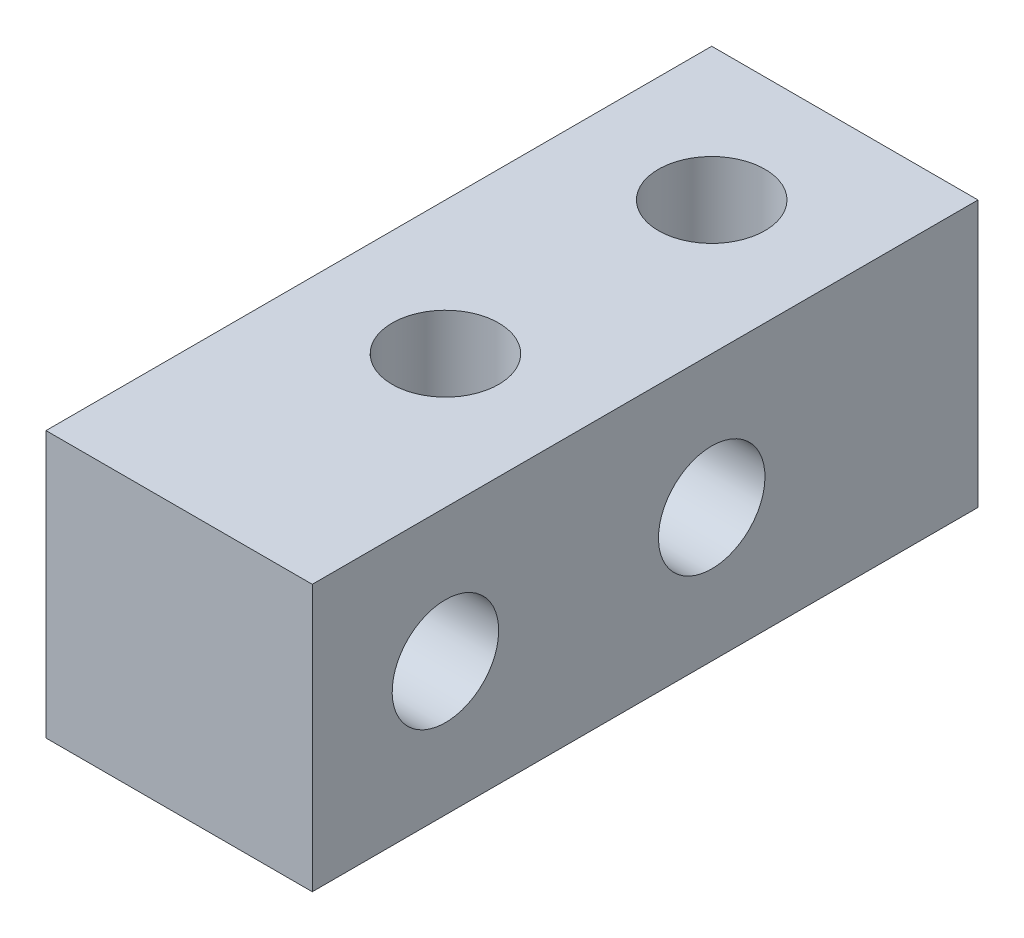
from build123d import *

# Parameters (mm, degrees)
SKETCH_1_W          = 10
SKETCH_1_H          = 10
EXTRUDE_1_DEPTH     = 12.5
SKETCH_2_R          = 2
CUT_EXTRUDE_1_DEPTH = 25
SKETCH_3_R          = 2
CUT_EXTRUDE_2_DEPTH = 25


with BuildPart() as part:
    # 草图1 → 凸台-拉伸1 (new body, symmetric)
    with BuildSketch(Plane.XY):
        Rectangle(SKETCH_1_W, SKETCH_1_H)
    extrude(amount=EXTRUDE_1_DEPTH, both=True)

    # 草图2 → 切除-拉伸1 (cut)
    with BuildSketch(Plane(origin=(5, 0, 0), x_dir=(0, 0, -1), z_dir=(1, 0, 0))):
        with Locations((-7.5, 0)):
            Circle(SKETCH_2_R)
        with Locations((2.5, 0)):
            Circle(SKETCH_2_R)
    extrude(amount=-CUT_EXTRUDE_1_DEPTH, mode=Mode.SUBTRACT)

    # 草图3 → 切除-拉伸2 (cut)
    with BuildSketch(Plane(origin=(0, 5, 0), x_dir=(1, 0, 0), z_dir=(0, 1, 0))):
        with Locations((0, 7.5)):
            Circle(SKETCH_3_R)
        with Locations((0, -2.5)):
            Circle(SKETCH_3_R)
    extrude(amount=-CUT_EXTRUDE_2_DEPTH, mode=Mode.SUBTRACT)


solid = part.part
